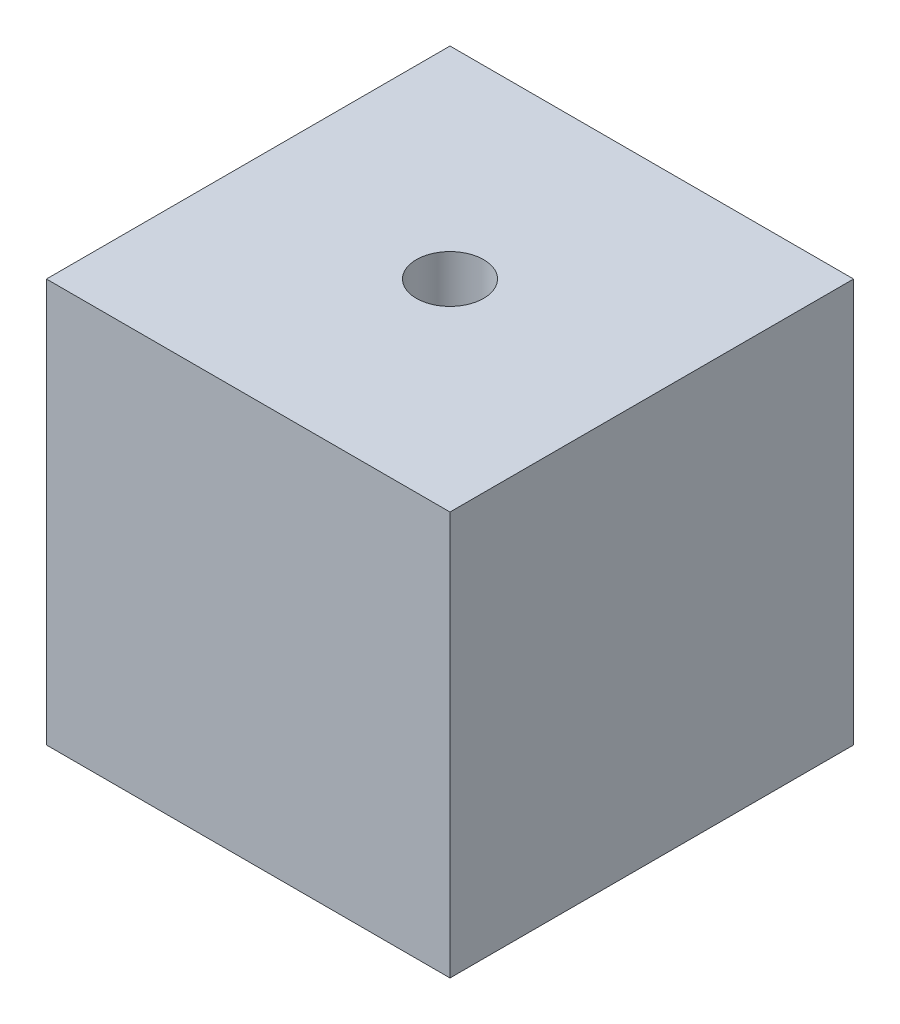
from build123d import *

# Parameters (mm, degrees)
SKETCH1_W           = 38.1
SKETCH1_H           = 38.1
BOSS_EXTRUDE1_DEPTH = 38.1
SKETCH2_R           = 3.175
CUT_EXTRUDE1_DEPTH  = 39.1


with BuildPart() as part:
    # Sketch1 → Boss-Extrude1 (new body)
    with BuildSketch(Plane.XY):
        with Locations((19.05, 19.05)):
            Rectangle(SKETCH1_W, SKETCH1_H)
    extrude(amount=BOSS_EXTRUDE1_DEPTH)

    # Sketch2 → Cut-Extrude1 (cut, through all)
    with BuildSketch(Plane(origin=(0, 38.1, 0), x_dir=(1, 0, 0), z_dir=(0, 1, 0))):
        with Locations((19.05, -19.05)):
            Circle(SKETCH2_R)
    extrude(amount=-CUT_EXTRUDE1_DEPTH, mode=Mode.SUBTRACT)


solid = part.part
